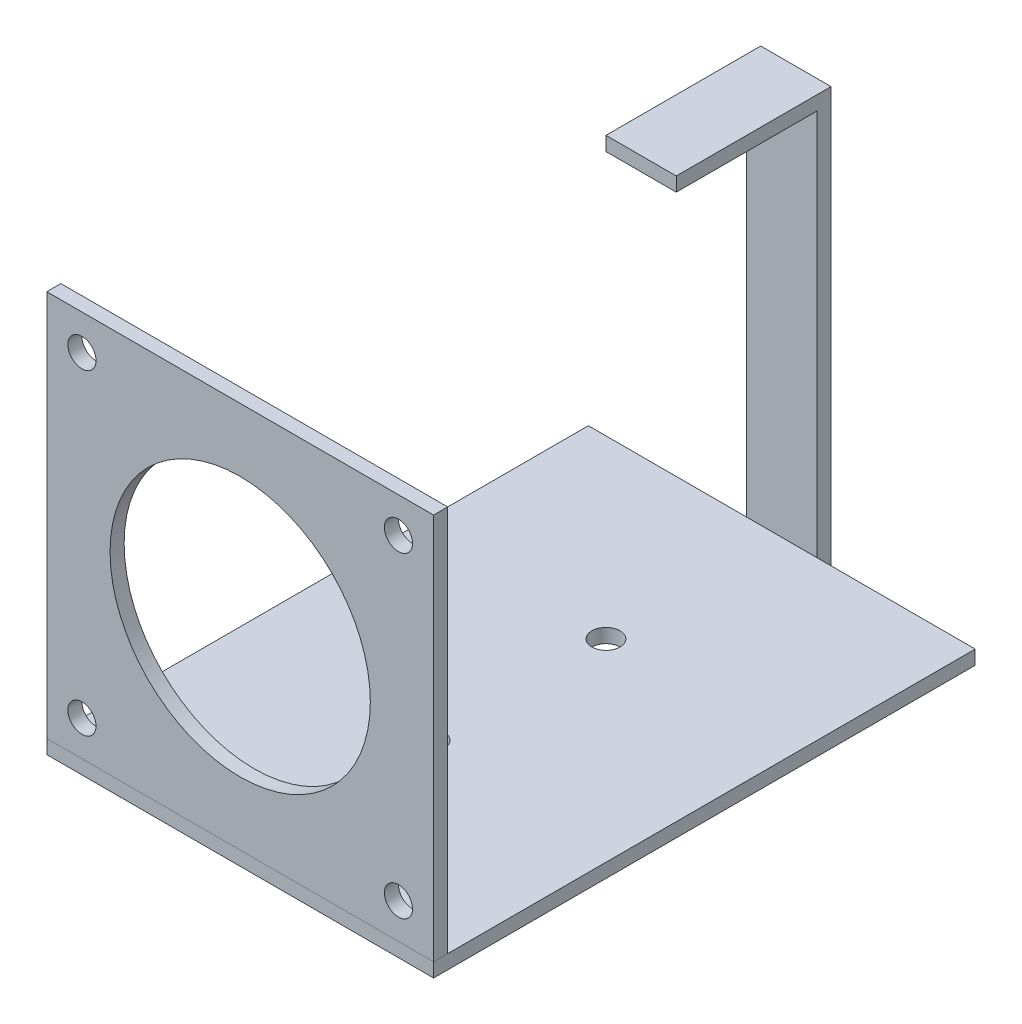
from build123d import *

# Parameters (mm, degrees)
SKETCH1_W           = 55
SKETCH1_H           = 55
SKETCH1_R           = 2
SKETCH1_R_2         = 18.5
BOSS_EXTRUDE1_DEPTH = 2
BOSS_EXTRUDE2_DEPTH = 55
BOSS_EXTRUDE3_DEPTH = 2
SKETCH4_W           = 10
SKETCH4_H           = 22
BOSS_EXTRUDE4_DEPTH = 2
SKETCH5_R           = 2
CUT_EXTRUDE1_DEPTH  = 2


with BuildPart() as part:
    # Sketch1 → Boss-Extrude1 (new body)
    with BuildSketch(Plane.XY):
        Rectangle(SKETCH1_W, SKETCH1_H)
        with Locations((-22.5, 22.5)):
            Circle(SKETCH1_R, mode=Mode.SUBTRACT)
        with Locations((22.5, 22.5)):
            Circle(SKETCH1_R, mode=Mode.SUBTRACT)
        with Locations((-22.5, -22.5)):
            Circle(SKETCH1_R, mode=Mode.SUBTRACT)
        with Locations((22.5, -22.5)):
            Circle(SKETCH1_R, mode=Mode.SUBTRACT)
        Circle(SKETCH1_R_2, mode=Mode.SUBTRACT)
    extrude(amount=BOSS_EXTRUDE1_DEPTH)


with BuildPart() as body_2:
    # Sketch2 → Boss-Extrude2 (new body)
    with BuildSketch(Plane(origin=(27.5, 0, 0), x_dir=(0, 0, -1), z_dir=(1, 0, 0))):
        Polygon((0, -27.5), (75, -27.5), (75, -29.5), (-2, -29.5), (-2, -27.5), align=None)
    extrude(amount=-BOSS_EXTRUDE2_DEPTH)

    # Sketch3 → Boss-Extrude3 (add)
    with BuildSketch(Plane(origin=(0, 0, -75), x_dir=(-1, 0, 0), z_dir=(0, 0, -1))):
        Polygon((0, -29.5), (-5, -29.5), (-5, 27.5), (5, 27.5), (5, -29.5), align=None)
    extrude(amount=BOSS_EXTRUDE3_DEPTH)

    # Sketch4 → Boss-Extrude4 (add)
    with BuildSketch(Plane(origin=(0, 27.5, 0), x_dir=(1, 0, 0), z_dir=(0, 1, 0))):
        with Locations((0, 66)):
            Rectangle(SKETCH4_W, SKETCH4_H)
    extrude(amount=BOSS_EXTRUDE4_DEPTH)

    # Sketch5 → Cut-Extrude1 (cut)
    with BuildSketch(Plane.XZ.offset(29.5)):
        with Locations((0, -25)):
            Circle(SKETCH5_R)
        with Locations((0, -50)):
            Circle(SKETCH5_R)
    extrude(amount=-CUT_EXTRUDE1_DEPTH, mode=Mode.SUBTRACT)


solid = Compound([part.part, body_2.part])
